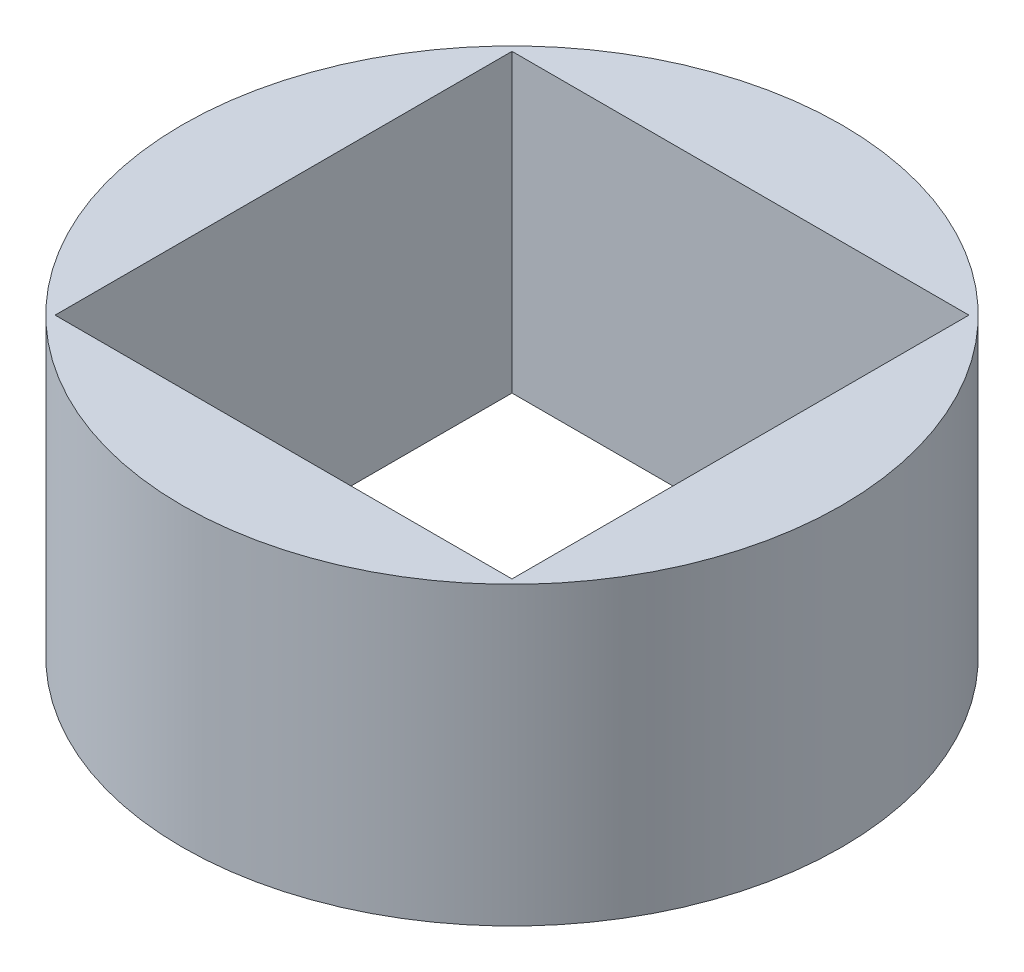
from build123d import *

# Parameters (mm, degrees)
SKETCH1_R           = 1.27
BOSS_EXTRUDE1_DEPTH = 1.14
SKETCH2_W           = 1.76
SKETCH2_H           = 1.76
CUT_EXTRUDE2_DEPTH  = 1.14


with BuildPart() as part:
    # Sketch1 → Boss-Extrude1 (new body)
    with BuildSketch(Plane(origin=(0, 0, 0), x_dir=(1, 0, 0), z_dir=(0, 1, 0))):
        Circle(SKETCH1_R)
    extrude(amount=BOSS_EXTRUDE1_DEPTH)

    # Sketch2 → Cut-Extrude2 (cut)
    with BuildSketch(Plane(origin=(0, 1.14, 0), x_dir=(1, 0, 0), z_dir=(0, 1, 0))):
        Rectangle(SKETCH2_W, SKETCH2_H)
    extrude(amount=-CUT_EXTRUDE2_DEPTH, mode=Mode.SUBTRACT)


solid = part.part
